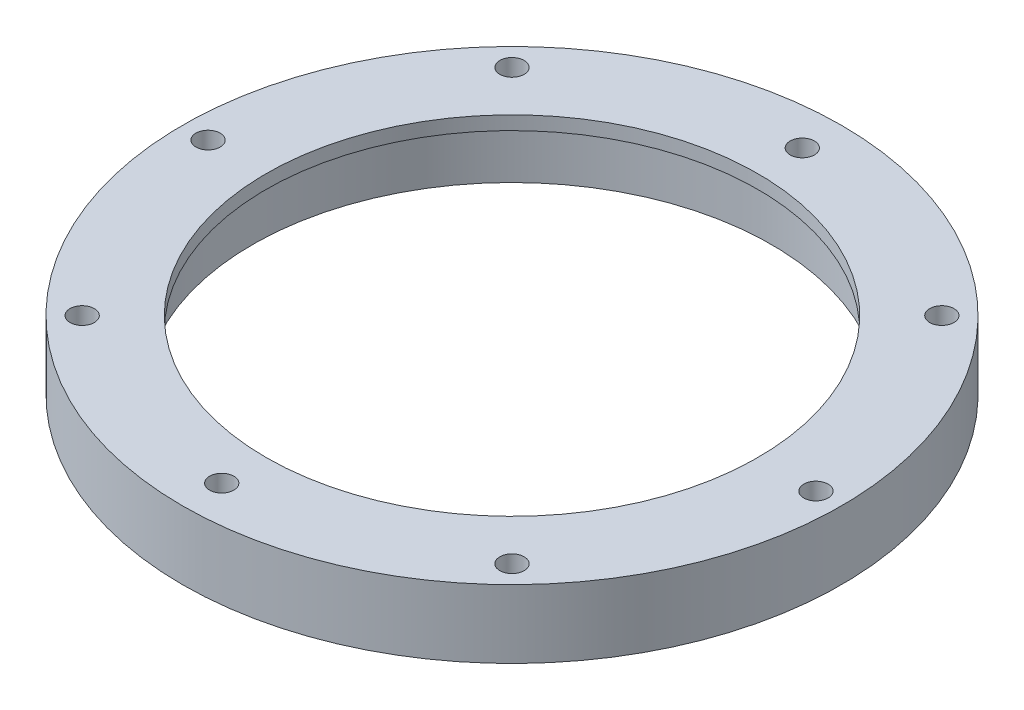
from build123d import *

# Parameters (mm, degrees)
SKETCH_1_R               = 48.25
SKETCH_1_R_2             = 38
EXTRUDE_1_DEPTH          = 10
SKETCH_2_R               = 38
SKETCH_2_R_2             = 36
EXTRUDE_2_DEPTH          = 2
SKETCH_3_R               = 1.775
CUT_EXTRUDE_1_DEPTH      = 1
CUT_EXTRUDE_1_DEPTH_BACK = 11
SKETCH_4_R               = 2
EXTRUDE_3_DEPTH          = 10
SKETCH_5_R               = 1.775
CUT_EXTRUDE_2_DEPTH      = 10


with BuildPart() as part:
    # 草图1 → 凸台-拉伸1 (new body)
    with BuildSketch(Plane(origin=(0, 0, 0), x_dir=(1, 0, 0), z_dir=(0, 1, 0))):
        Circle(SKETCH_1_R)
        Circle(SKETCH_1_R_2, mode=Mode.SUBTRACT)
    extrude(amount=EXTRUDE_1_DEPTH)

    # 草图2 → 凸台-拉伸2 (add)
    with BuildSketch(Plane(origin=(0, 10, 0), x_dir=(1, 0, 0), z_dir=(0, 1, 0))):
        Circle(SKETCH_2_R)
        Circle(SKETCH_2_R_2, mode=Mode.SUBTRACT)
    extrude(amount=-EXTRUDE_2_DEPTH)

    # 草图3 → 切除-拉伸1 (cut, two sides)
    with BuildSketch(Plane.XZ) as cut_extrude_1_sk:
        with Locations((0, 44.5)):
            Circle(SKETCH_3_R)
        with Locations((31.466251763, 31.466251763)):
            Circle(SKETCH_3_R)
        with Locations((44.5, 0)):
            Circle(SKETCH_3_R)
        with Locations((31.466251763, -31.466251763)):
            Circle(SKETCH_3_R)
        with Locations((0, -44.5)):
            Circle(SKETCH_3_R)
        with Locations((-31.466251763, -31.466251763)):
            Circle(SKETCH_3_R)
        with Locations((-44.5, 0)):
            Circle(SKETCH_3_R)
        with Locations((-31.466251763, 31.466251763)):
            Circle(SKETCH_3_R)
    extrude(amount=CUT_EXTRUDE_1_DEPTH, mode=Mode.SUBTRACT)
    extrude(cut_extrude_1_sk.sketch, amount=-CUT_EXTRUDE_1_DEPTH_BACK, mode=Mode.SUBTRACT)

    # 草图4 → 凸台-拉伸3 (add)
    with BuildSketch(Plane(origin=(0, 10, 0), x_dir=(1, 0, 0), z_dir=(0, 1, 0))):
        with Locations((0, -44.5)):
            Circle(SKETCH_4_R)
        with Locations((0, 44.5)):
            Circle(SKETCH_4_R)
    extrude(amount=-EXTRUDE_3_DEPTH)

    # 草图5 → 切除-拉伸2 (cut)
    with BuildSketch(Plane(origin=(0, 10, 0), x_dir=(1, 0, 0), z_dir=(0, 1, 0))):
        with Locations((5.5258e-05, -42.50007959)):
            Circle(SKETCH_5_R)
        with Locations((2.4326e-05, 42.499999999)):
            Circle(SKETCH_5_R)
    extrude(amount=-CUT_EXTRUDE_2_DEPTH, mode=Mode.SUBTRACT)


solid = part.part
